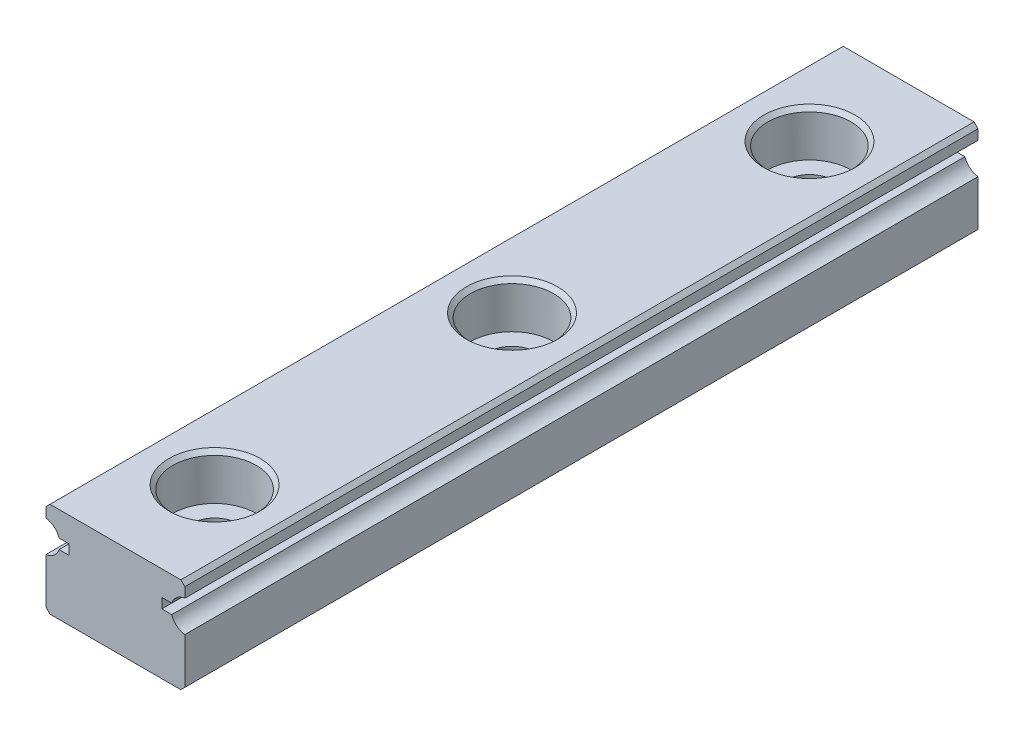
from build123d import *

# Parameters (mm, degrees)
EXTRUDE1_DEPTH             = 40
EXTRUDE2_REACH             = 42.439
SKETCH2_R                  = 1.2
SKETCH_R                   = 2.1
SKETCH_R_2                 = 1.2
EXTRUDE4_DEPTH             = 2.3
CHAMFER1_SIZE              = 0.2
LPATTERN1_COUNT            = 3
LPATTERN1_PITCH            = 15
CHAMFER1_OF_LPATTERN1_SIZE = 0.2


with BuildPart() as part:
    # Sketch1 → Extrude1 (new body)
    with BuildSketch(Plane.XY):
        with BuildLine():
            Line((-3.3, -2.4), (3.3, -2.4))
            Line((3.3, -2.4), (3.5, -2.2))
            Line((3.5, -2.2), (3.5, 0.106274607))
            ThreePointArc((3.5, 0.106274607), (3.091294745, 0.282570681), (2.840065792, 0.65))
            Line((2.840065792, 0.65), (2.340065792, 0.65))
            Line((2.340065792, 0.65), (2.340065792, 1.15))
            Line((2.340065792, 1.15), (2.840065792, 1.15))
            ThreePointArc((2.840065792, 1.15), (3.091294745, 1.517429319), (3.5, 1.693725393))
            Line((3.5, 1.693725393), (3.5, 2.2))
            Line((3.5, 2.2), (3.3, 2.4))
            Line((3.3, 2.4), (-3.3, 2.4))
            Line((-3.3, 2.4), (-3.5, 2.2))
            Line((-3.5, 2.2), (-3.5, 1.693725393))
            ThreePointArc((-3.5, 1.693725393), (-3.091294745, 1.517429319), (-2.840065792, 1.15))
            Line((-2.840065792, 1.15), (-2.340065792, 1.15))
            Line((-2.340065792, 1.15), (-2.340065792, 0.65))
            Line((-2.340065792, 0.65), (-2.840065792, 0.65))
            ThreePointArc((-2.840065792, 0.65), (-3.091294745, 0.282570681), (-3.5, 0.106274607))
            Line((-3.5, 0.106274607), (-3.5, -2.2))
            Line((-3.5, -2.2), (-3.3, -2.4))
        make_face()
    extrude(amount=EXTRUDE1_DEPTH)

    # Sketch2 → Extrude2 (cut, up to next)
    with BuildSketch(Plane(origin=(0, 2.4, 0), x_dir=(1, 0, 0), z_dir=(0, 1, 0)), mode=Mode.PRIVATE) as extrude2_sk1:
        with Locations((0, -5)):
            Circle(SKETCH2_R)
    extrude2_tool1 = extrude(extrude2_sk1.sketch, amount=-EXTRUDE2_REACH, mode=Mode.PRIVATE) & part.part
    extrude2 = extrude2_tool1.solids().sort_by_distance((0, 2.4, 5))[0]
    add(extrude2, mode=Mode.SUBTRACT)

    # Sketch → Extrude4 (cut)
    with BuildSketch(Plane(origin=(0, 2.4, 0), x_dir=(1, 0, 0), z_dir=(0, 1, 0))):
        with Locations((0, -5)):
            Circle(SKETCH_R)
        with Locations((0, -5)):
            Circle(SKETCH_R_2, mode=Mode.SUBTRACT)
    extrude4 = extrude(amount=-EXTRUDE4_DEPTH, mode=Mode.SUBTRACT)

    # Chamfer1
    chamfer1_edges = [part.edges().sort_by_distance(p)[0] for p in [
        (-1.2, -2.4, 5),
        (-2.1, 2.4, 5),
    ]]
    chamfer(chamfer1_edges, length=CHAMFER1_SIZE)

    # LPattern1: Extrude2, Extrude4 ×3
    with Locations(*[(0, 0, i * LPATTERN1_PITCH) for i in range(1, LPATTERN1_COUNT)]):
        add(extrude2, mode=Mode.SUBTRACT)
        add(extrude4, mode=Mode.SUBTRACT)

    # Chamfer1 of LPattern1
    chamfer1_of_lpattern1_edges = [part.edges().sort_by_distance(p)[0] for p in [
        (-1.2, -2.4, 20),
        (-2.1, 2.4, 20),
        (-1.2, -2.4, 35),
        (-2.1, 2.4, 35),
    ]]
    chamfer(chamfer1_of_lpattern1_edges, length=CHAMFER1_OF_LPATTERN1_SIZE)


solid = part.part
